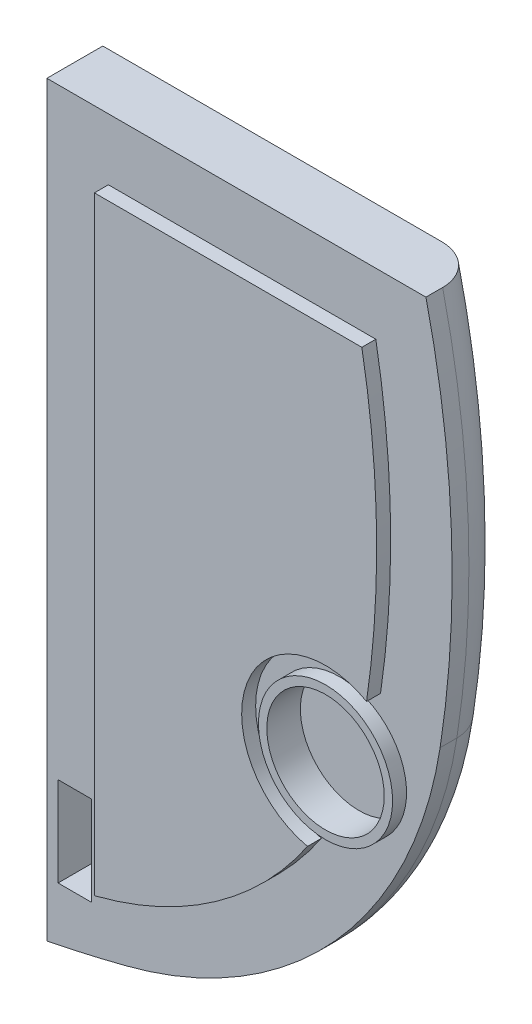
from build123d import *

# Parameters (mm, degrees)
BOSS_EXTRUDE1_DEPTH = 10
FILLET1_R           = 7
BOSS_EXTRUDE2_DEPTH = 2.5
SKETCH8_W           = 6
SKETCH8_H           = 16
CUT_EXTRUDE1_DEPTH  = 6
SKETCH9_R           = 12
BOSS_EXTRUDE3_DEPTH = 2.5
SKETCH10_R          = 10.5
CUT_EXTRUDE2_DEPTH  = 6


with BuildPart() as part:
    # Sketch1 → Boss-Extrude1 (new body)
    with BuildSketch(Plane.XY):
        with BuildLine():
            Line((0, 0), (67.8, 0))
            ThreePointArc((67.8, 0), (72.369764115, -34.141185106), (70.341123561, -68.527052581))
            ThreePointArc((70.341123561, -68.527052581), (51.546832931, -107.857068487), (14.233546266, -130.391356799))
            ThreePointArc((14.233546266, -130.391356799), (7.138727746, -132.120022188), (0, -133.657325027))
            Line((0, -133.657325027), (0, 0))
        make_face()
    extrude(amount=BOSS_EXTRUDE1_DEPTH)

    # Fillet1
    fillet1_edges = [part.edges().sort_by_distance(p)[0] for p in [
        (72.369764115, -34.141185106, 0),
        (51.546832931, -107.857068487, 0),
        (7.138727746, -132.120022188, 0),
    ]]
    fillet(fillet1_edges, radius=FILLET1_R)

    # Sketch7 → Boss-Extrude2 (add)
    with BuildSketch(Plane.XY.offset(10)):
        with BuildLine():
            Line((11, -11), (11, -119.864879644))
            ThreePointArc((11, -119.864879644), (11.243089625, -119.802551163), (11.486119117, -119.739988621))
            ThreePointArc((11.486119117, -119.739988621), (32.734504551, -109.903861987), (49.119007756, -93.176897964))
            ThreePointArc((49.119007756, -93.176897964), (38.323820757, -73.187087964), (59.682991081, -65.446648104))
            ThreePointArc((59.682991081, -65.446648104), (61.472976924, -38.189093901), (58.840205899, -11))
            Line((58.840205899, -11), (11, -11))
        make_face()
    extrude(amount=BOSS_EXTRUDE2_DEPTH)

    # Sketch8 → Cut-Extrude1 (cut)
    with BuildSketch(Plane.XY.offset(10)):
        with Locations((5, -115.657325027)):
            Rectangle(SKETCH8_W, SKETCH8_H)
    extrude(amount=-CUT_EXTRUDE1_DEPTH, mode=Mode.SUBTRACT)

    # Sketch9 → Boss-Extrude3 (add)
    with BuildSketch(Plane.XY.offset(10)):
        with Locations((52.341123561, -78.527052581)):
            Circle(SKETCH9_R)
    extrude(amount=BOSS_EXTRUDE3_DEPTH)

    # Sketch10 → Cut-Extrude2 (cut)
    with BuildSketch(Plane.XY.offset(12.5)):
        with Locations((52.341123561, -78.527052581)):
            Circle(SKETCH10_R)
    extrude(amount=-CUT_EXTRUDE2_DEPTH, mode=Mode.SUBTRACT)


solid = part.part
